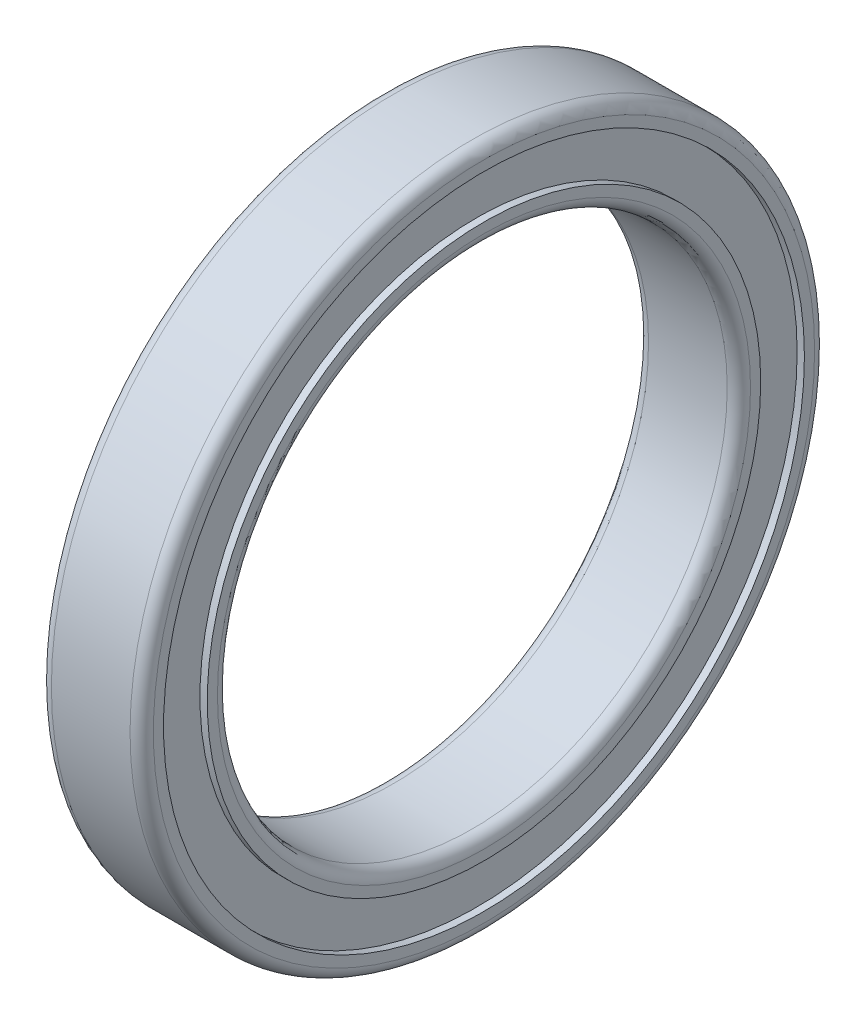
from build123d import *

# Parameters (mm, degrees)
FILLET_1_R = 0.8


with BuildPart() as part:
    # Эскиз1 → Повернуть1 (revolve)
    with BuildSketch(Plane.XY):
        Polygon((3.5, 17.5), (-3.5, 17.5), (-3.5, 19), (-3, 19), (-3, 22), (-3.5, 22), (-3.5, 23.5), (3.5, 23.5), (3.5, 22), (3, 22), (3, 19), (3.5, 19), align=None)
    revolve(axis=Axis((0, 0, 0), (-1, 0, 0)))

    # Скругление1
    fillet_1_edges = [part.edges().sort_by_distance(p)[0] for p in [
        (-3.5, -23.5, 0),
        (3.5, -23.5, 0),
        (3.5, -17.5, 0),
        (-3.5, -17.5, 0),
    ]]
    fillet(fillet_1_edges, radius=FILLET_1_R)


solid = part.part
